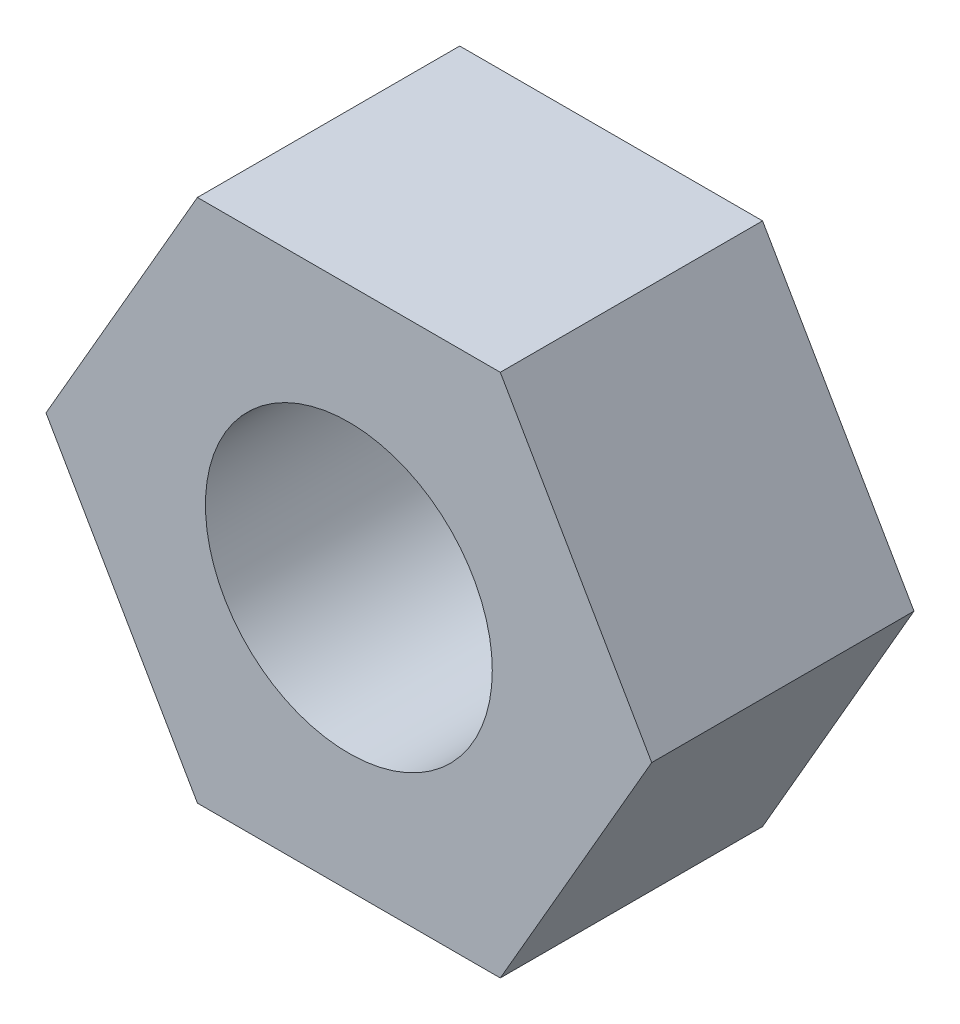
from build123d import *

# Parameters (mm, degrees)
EXTRUDE1_DEPTH        = 6.4
M8X1_0_TAPPED_HOLE1_D = 7


with BuildPart() as part:
    # Sketch1 → Extrude1 (new body)
    with BuildSketch(Plane.XY):
        Polygon((7.390083446, 0), (3.695041723, 6.4), (-3.695041723, 6.4), (-7.390083446, 0), (-3.695041723, -6.4), (3.695041723, -6.4), align=None)
    extrude(amount=EXTRUDE1_DEPTH)

    # M8x1.0 Tapped Hole1 (through all)
    with Locations(Plane.XY.offset(6.4)):
        with Locations((0, 0)):
            Hole(M8X1_0_TAPPED_HOLE1_D / 2)


solid = part.part
